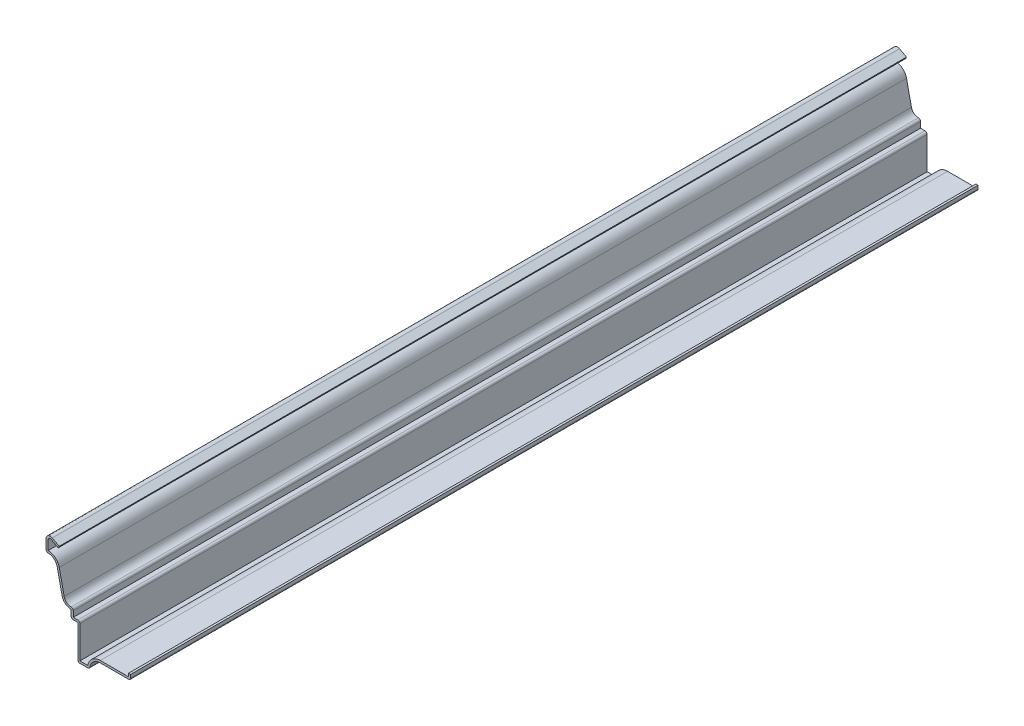
from build123d import *

# Parameters (mm, degrees)
EXTRUDE_THIN1_DEPTH = 508
FILLET1_R           = 1.27


with BuildPart() as part:
    # Sketch1 → Extrude-Thin1 (new body)
    with BuildSketch(Plane.XY):
        with BuildLine():
            Line((0, 9.525), (0, 6.35))
            Line((0, 6.35), (-18.25625, 6.35))
            ThreePointArc((-18.25625, 6.35), (-22.746378061, 4.490128061), (-24.60625, 0))
            Line((-24.60625, 0), (-31.75, 0))
            Line((-31.75, 0), (-31.75, 20.6375))
            Line((-31.75, 20.6375), (-35.71875, 20.6375))
            Line((-35.71875, 20.6375), (-35.71875, 25.4))
            ThreePointArc((-35.71875, 25.4), (-39.20672008, 26.631209101), (-41.148892003, 29.779189303))
            Line((-41.148892003, 29.779189303), (-44.099857997, 43.392900498))
            ThreePointArc((-44.099857997, 43.392900498), (-46.562785495, 46.913451124), (-50.8, 47.625))
            Line((-50.8, 47.625), (-50.8, 54.61))
            ThreePointArc((-50.8, 54.61), (-49.566819219, 56.788032031), (-47.064705882, 56.851176471))
            Line((-47.064705882, 56.851176471), (-42.8625, 54.61))
            Line((-42.8625, 54.61), (-43.460147059, 53.489411765))
            Line((-43.460147059, 53.489411765), (-47.662352941, 55.730588235))
            ThreePointArc((-47.662352941, 55.730588235), (-48.913409609, 55.699016016), (-49.53, 54.61))
            Line((-49.53, 54.61), (-49.53, 49.042089801))
            ThreePointArc((-49.53, 49.042089801), (-45.244779615, 47.529461477), (-42.858682681, 43.661942943))
            Line((-42.858682681, 43.661942943), (-39.907716688, 30.048231748))
            ThreePointArc((-39.907716688, 30.048231748), (-37.879157823, 27.254280646), (-34.44875, 26.862469466))
            Line((-34.44875, 26.862469466), (-34.44875, 21.9075))
            Line((-34.44875, 21.9075), (-30.48, 21.9075))
            Line((-30.48, 21.9075), (-30.48, 1.27))
            Line((-30.48, 1.27), (-25.769671325, 1.27))
            ThreePointArc((-25.769671325, 1.27), (-23.17493885, 5.819871133), (-18.25625, 7.62))
            Line((-18.25625, 7.62), (-1.27, 7.62))
            Line((-1.27, 7.62), (-1.27, 9.525))
            Line((-1.27, 9.525), (0, 9.525))
        make_face()
    extrude(amount=-EXTRUDE_THIN1_DEPTH)

    # Fillet1
    fillet1_edges = [part.edges().sort_by_distance(p)[0] for p in [
        (-34.44875, 26.862469466, -254),
        (-30.48, 21.9075, -254),
        (0, 6.35, -254),
        (-24.60625, 0, -254),
        (-31.75, 0, -254),
        (-35.71875, 20.6375, -254),
        (-50.8, 47.625, -254),
    ]]
    fillet(fillet1_edges, radius=FILLET1_R)


solid = part.part
